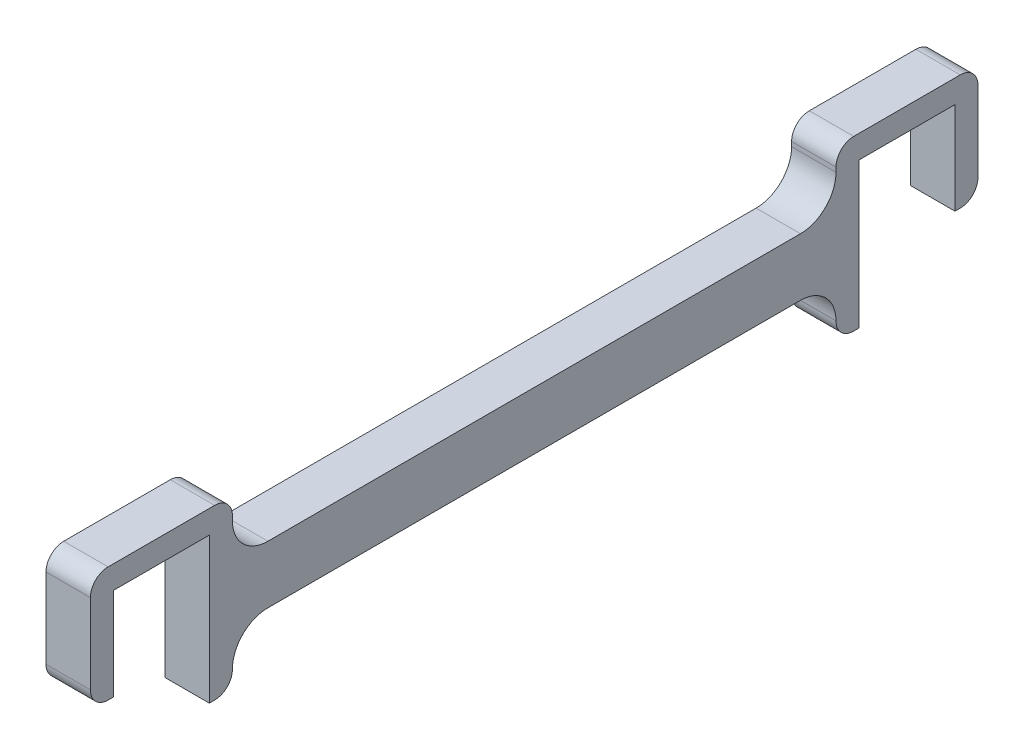
from build123d import *

# Parameters (mm, degrees)
BOSS_EXTRUDE1_DEPTH = 5


with BuildPart() as part:
    # Sketch1 → Boss-Extrude1 (new body)
    with BuildSketch(Plane(origin=(0, 0, 0), x_dir=(0, -1, 0), z_dir=(1, 0, 0))):
        with BuildLine():
            Line((-81, -13.4), (-87, -13.4))
            Line((-87, -13.4), (-97.4, -13.4))
            Line((-97.4, -13.4), (-97.4, -2.6))
            Line((-97.4, -2.6), (-87, -2.6))
            Line((-87, -2.6), (-87, -2))
            ThreePointArc((-87, -2), (-87.585786438, -0.585786438), (-89, 0))
            Line((-89, 0), (-98, 0))
            ThreePointArc((-98, 0), (-99.414213562, -0.585786438), (-100, -2))
            Line((-100, -2), (-100, -14))
            ThreePointArc((-100, -14), (-99.414213562, -15.414213562), (-98, -16))
            Line((-98, -16), (-97.5, -16))
            ThreePointArc((-97.5, -16), (-94.671572875, -17.171572875), (-93.5, -20))
            Line((-93.5, -20), (-93.5, -80))
            ThreePointArc((-93.5, -80), (-94.671572875, -82.828427125), (-97.5, -84))
            Line((-97.5, -84), (-98, -84))
            ThreePointArc((-98, -84), (-99.414213562, -84.585786438), (-100, -86))
            Line((-100, -86), (-100, -98))
            ThreePointArc((-100, -98), (-99.414213562, -99.414213562), (-98, -100))
            Line((-98, -100), (-89, -100))
            ThreePointArc((-89, -100), (-87.585786438, -99.414213562), (-87, -98))
            Line((-87, -98), (-87, -97.4))
            Line((-87, -97.4), (-97.4, -97.4))
            Line((-97.4, -97.4), (-97.4, -86.6))
            Line((-97.4, -86.6), (-87, -86.6))
            Line((-87, -86.6), (-81, -86.6))
            Line((-81, -86.6), (-81, -86))
            Line((-81, -86), (-81, -85.99))
            ThreePointArc((-81, -85.99), (-81.582857505, -84.582857505), (-82.99, -84))
            Line((-82.99, -84), (-83, -84))
            Line((-83, -84), (-83.01, -84))
            ThreePointArc((-83.01, -84), (-85.831356057, -82.831356057), (-87, -80.01))
            Line((-87, -80.01), (-87, -80))
            Line((-87, -80), (-87, -20))
            Line((-87, -20), (-87, -19.99))
            ThreePointArc((-87, -19.99), (-85.831356057, -17.168643943), (-83.01, -16))
            Line((-83.01, -16), (-83, -16))
            Line((-83, -16), (-82.99, -16))
            ThreePointArc((-82.99, -16), (-81.582857505, -15.417142495), (-81, -14.01))
            Line((-81, -14.01), (-81, -14))
            Line((-81, -14), (-81, -13.4))
        make_face()
    extrude(amount=BOSS_EXTRUDE1_DEPTH)


solid = part.part
